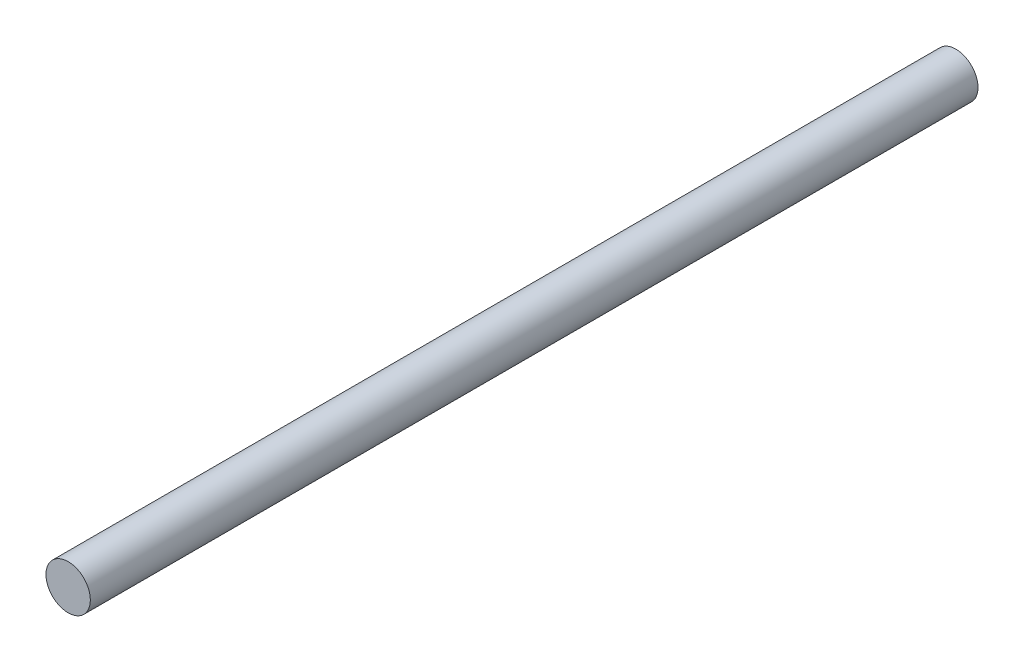
from build123d import *

# Parameters (mm, degrees)
SCHIZZO1_R                   = 2.5
ESTRUSIONE_ESTRUSIONE1_DEPTH = 100
SCHIZZO2_R                   = 0.5
TAGLIO_ESTRUSIONE1_DEPTH     = 3.5
SCHIZZO3_R                   = 0.5
TAGLIO_ESTRUSIONE2_DEPTH     = 3.5000001


with BuildPart() as part:
    # Schizzo1 → Estrusione-Estrusione1 (new body)
    with BuildSketch(Plane.XY):
        Circle(SCHIZZO1_R)
    extrude(amount=ESTRUSIONE_ESTRUSIONE1_DEPTH)

    # Schizzo2 → Taglio-Estrusione1 (cut, through all)
    with BuildSketch(Plane(origin=(0, 0, 0), x_dir=(1, 0, 0), z_dir=(0, 1, 0))):
        with Locations((0, -1)):
            Circle(SCHIZZO2_R)
    extrude(amount=-TAGLIO_ESTRUSIONE1_DEPTH, mode=Mode.SUBTRACT)

    # Schizzo3 → Taglio-Estrusione2 (cut, through all)
    with BuildSketch(Plane(origin=(0, 0, 0), x_dir=(1, 0, 0), z_dir=(0, 1, 0))):
        with Locations((0, -99)):
            Circle(SCHIZZO3_R)
    extrude(amount=-TAGLIO_ESTRUSIONE2_DEPTH, mode=Mode.SUBTRACT)


solid = part.part
